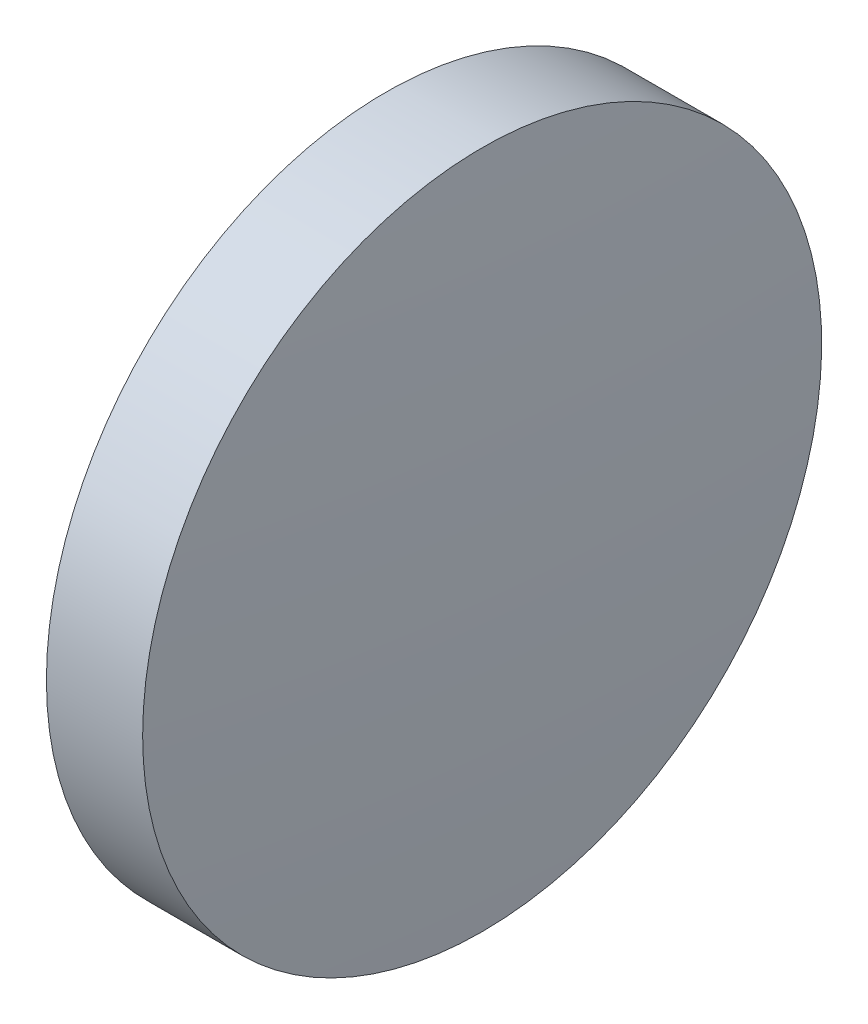
from build123d import *


with BuildPart() as part:
    # 草图1 → 旋转1 (revolve)
    with BuildSketch(Plane.XY, mode=Mode.PRIVATE) as revolve_1_sk:
        with BuildLine():
            Line((430.097522609, 147.01901943), (430.097522609, 159.71901943))
            Line((430.097522609, 159.71901943), (433.697522609, 159.71901943))
            ThreePointArc((433.697522609, 159.71901943), (433.997497821, 153.372168255), (434.097522609, 147.01901943))
            Line((434.097522609, 147.01901943), (430.097522609, 147.01901943))
        make_face()
    revolve(revolve_1_sk.sketch.rotate(Axis((424.467626558, 147.01901943, 0), (1, 0, 0)), 180), axis=Axis((424.467626558, 147.01901943, 0), (1, 0, 0)))  # turned: the seam where the file's is


solid = part.part
